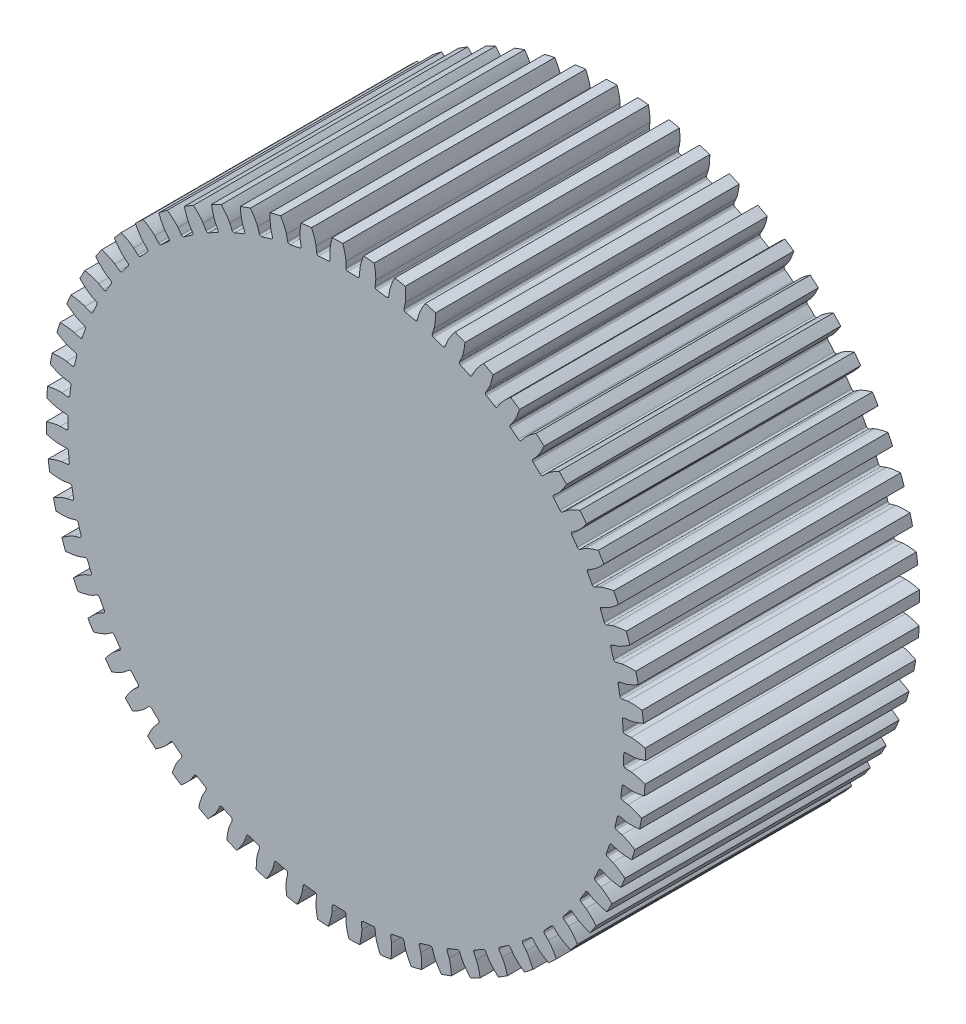
from build123d import *

# Parameters (mm, degrees)
SKETCH1_R                 = 24.045217391
BOSS_EXTRUDE1_DEPTH       = 22.008152455
CUT_EXTRUDE3_START        = -1
CUT_EXTRUDE3_DEPTH        = 24.008152455
FILLET1_R                 = 0.15
CIRPATTERN16_COUNT        = 60
FILLET1_OF_CIRPATTERN16_R = 0.15


with BuildPart() as part:
    # Sketch1 → Boss-Extrude1 (new body)
    with BuildSketch(Plane.XY):
        Circle(SKETCH1_R)
    extrude(amount=BOSS_EXTRUDE1_DEPTH)

    # Sketch2 → Cut-Extrude3 (cut)
    with BuildSketch(Plane.XY.offset(CUT_EXTRUDE3_START)):
        with BuildLine():
            Line((22.916048235, 0), (22.3, 0))
            ThreePointArc((22.3, 0), (22.293369744, -0.543751301), (22.273482917, -1.087179265))
            Line((22.273482917, -1.087179265), (22.888798605, -1.117213115))
            add(Edge.make_bspline(
                [(22.888798605, -1.117213115), (22.905702884, -1.118397162), (22.953024426, -1.122824922), (23.042075226, -1.135557831), (23.186481882, -1.162501344), (23.368907891, -1.205830137), (23.601505715, -1.271830611), (23.790604711, -1.335170026), (23.924319999, -1.384131111), (24.003573033, -1.414553296)],
                knots=[0, 0, 0, 0, 0, 0.005376748, 0.015083688, 0.02853182, 0.046610139, 0.064854849, 0.091796625, 0.091796625, 0.091796625, 0.091796625, 0.091796625], degree=4))
            ThreePointArc((24.003573033, -1.414553296), (24.034804047, -0.707583084), (24.045217391, 0))
            ThreePointArc((24.045217391, 0), (24.044911325, 0.121320867), (24.043993135, 0.242638646))
            add(Edge.make_bspline(
                [(22.916048235, 0), (22.932990139, 0.000358514), (22.980471274, 0.002473968), (23.070036944, 0.010850294), (23.215585447, 0.030721592), (23.399906915, 0.065105151), (23.635445839, 0.119687433), (23.827407927, 0.173732494), (23.963351185, 0.216116414), (24.043993135, 0.242638646)],
                knots=[0, 0, 0, 0, 0, 0.005376748, 0.015083688, 0.02853182, 0.046610139, 0.064854849, 0.091796625, 0.091796625, 0.091796625, 0.091796625, 0.091796625], degree=4))
        make_face()
    cut_extrude3 = extrude(amount=CUT_EXTRUDE3_DEPTH, mode=Mode.SUBTRACT)

    # Fillet1
    fillet1_edges = [part.edges().sort_by_distance(p)[0] for p in [
        (22.3, 0, 11.004076227),
        (22.273482917, -1.087179265, 11.004076227),
    ]]
    fillet(fillet1_edges, radius=FILLET1_R)

    # CirPattern16: Cut-Extrude3 ×60 about axis
    cirpattern16_axis = Axis((0, 0, 22.008152455), (0, 0, -1))
    for i in range(1, CIRPATTERN16_COUNT):
        add(cut_extrude3.rotate(cirpattern16_axis, i * 360 / CIRPATTERN16_COUNT), mode=Mode.SUBTRACT)

    # Fillet1 of CirPattern16
    fillet1_of_cirpattern16_edges = [part.edges().sort_by_distance(p)[0] for p in [
        (22.177838267, -2.330984731, 11.004076227),
        (22.037825269, -3.409436524, 11.004076227),
        (21.812691496, -4.636430705, 11.004076227),
        (21.560716596, -5.694339283, 11.004076227),
        (21.208560313, -6.891078975, 11.004076227),
        (20.8473842, -7.916853669, 11.004076227),
        (20.372063705, -9.070227141, 11.004076227),
        (19.9056435, -10.05262935, 11.004076227),
        (19.312366504, -11.15, 11.004076227),
        (18.745812404, -12.07826632, 11.004076227),
        (18.041078975, -13.107611126, 11.004076227),
        (17.380598265, -13.971571277, 11.004076227),
        (16.572129608, -14.921612522, 11.004076227),
        (15.824958654, -15.711800775, 11.004076227),
        (14.921612522, -16.572129608, 11.004076227),
        (14.095937485, -17.279888496, 11.004076227),
        (13.107611126, -18.041078975, 11.004076227),
        (12.212478275, -18.658654142, 11.004076227),
        (11.15, -19.312366504, 11.004076227),
        (10.195216597, -19.832991669, 11.004076227),
        (9.070227141, -20.372063705, 11.004076227),
        (8.066253992, -20.790034789, 11.004076227),
        (6.891078975, -21.208560313, 11.004076227),
        (5.848915821, -21.519297937, 11.004076227),
        (4.636430705, -21.812691496, 11.004076227),
        (3.567495704, -22.012791154, 11.004076227),
        (2.330984731, -22.177838267, 11.004076227),
        (1.246989358, -22.265107625, 11.004076227),
        (0, -22.3, 11.004076227),
        (-1.087179265, -22.273482917, 11.004076227),
        (-2.330984731, -22.177838267, 11.004076227),
        (-3.409436524, -22.037825269, 11.004076227),
        (-4.636430705, -21.812691496, 11.004076227),
        (-5.694339283, -21.560716596, 11.004076227),
        (-6.891078975, -21.208560313, 11.004076227),
        (-7.916853669, -20.8473842, 11.004076227),
        (-9.070227141, -20.372063705, 11.004076227),
        (-10.05262935, -19.9056435, 11.004076227),
        (-11.15, -19.312366504, 11.004076227),
        (-12.07826632, -18.745812404, 11.004076227),
        (-13.107611126, -18.041078975, 11.004076227),
        (-13.971571277, -17.380598265, 11.004076227),
        (-14.921612522, -16.572129608, 11.004076227),
        (-15.711800775, -15.824958654, 11.004076227),
        (-16.572129608, -14.921612522, 11.004076227),
        (-17.279888496, -14.095937485, 11.004076227),
        (-18.041078975, -13.107611126, 11.004076227),
        (-18.658654142, -12.212478275, 11.004076227),
        (-19.312366504, -11.15, 11.004076227),
        (-19.832991669, -10.195216597, 11.004076227),
        (-20.372063705, -9.070227141, 11.004076227),
        (-20.790034789, -8.066253992, 11.004076227),
        (-21.208560313, -6.891078975, 11.004076227),
        (-21.519297937, -5.848915821, 11.004076227),
        (-21.812691496, -4.636430705, 11.004076227),
        (-22.012791154, -3.567495704, 11.004076227),
        (-22.177838267, -2.330984731, 11.004076227),
        (-22.265107625, -1.246989358, 11.004076227),
        (-22.3, 0, 11.004076227),
        (-22.273482917, 1.087179265, 11.004076227),
        (-22.177838267, 2.330984731, 11.004076227),
        (-22.037825269, 3.409436524, 11.004076227),
        (-21.812691496, 4.636430705, 11.004076227),
        (-21.560716596, 5.694339283, 11.004076227),
        (-21.208560313, 6.891078975, 11.004076227),
        (-20.8473842, 7.916853669, 11.004076227),
        (-20.372063705, 9.070227141, 11.004076227),
        (-19.9056435, 10.05262935, 11.004076227),
        (-19.312366504, 11.15, 11.004076227),
        (-18.745812404, 12.07826632, 11.004076227),
        (-18.041078975, 13.107611126, 11.004076227),
        (-17.380598265, 13.971571277, 11.004076227),
        (-16.572129608, 14.921612522, 11.004076227),
        (-15.824958654, 15.711800775, 11.004076227),
        (-14.921612522, 16.572129608, 11.004076227),
        (-14.095937485, 17.279888496, 11.004076227),
        (-13.107611126, 18.041078975, 11.004076227),
        (-12.212478275, 18.658654142, 11.004076227),
        (-11.15, 19.312366504, 11.004076227),
        (-10.195216597, 19.832991669, 11.004076227),
        (-9.070227141, 20.372063705, 11.004076227),
        (-8.066253992, 20.790034789, 11.004076227),
        (-6.891078975, 21.208560313, 11.004076227),
        (-5.848915821, 21.519297937, 11.004076227),
        (-4.636430705, 21.812691496, 11.004076227),
        (-3.567495704, 22.012791154, 11.004076227),
        (-2.330984731, 22.177838267, 11.004076227),
        (-1.246989358, 22.265107625, 11.004076227),
        (0, 22.3, 11.004076227),
        (1.087179265, 22.273482917, 11.004076227),
        (2.330984731, 22.177838267, 11.004076227),
        (3.409436524, 22.037825269, 11.004076227),
        (4.636430705, 21.812691496, 11.004076227),
        (5.694339283, 21.560716596, 11.004076227),
        (6.891078975, 21.208560313, 11.004076227),
        (7.916853669, 20.8473842, 11.004076227),
        (9.070227141, 20.372063705, 11.004076227),
        (10.05262935, 19.9056435, 11.004076227),
        (11.15, 19.312366504, 11.004076227),
        (12.07826632, 18.745812404, 11.004076227),
        (13.107611126, 18.041078975, 11.004076227),
        (13.971571277, 17.380598265, 11.004076227),
        (14.921612522, 16.572129608, 11.004076227),
        (15.711800775, 15.824958654, 11.004076227),
        (16.572129608, 14.921612522, 11.004076227),
        (17.279888496, 14.095937485, 11.004076227),
        (18.041078975, 13.107611126, 11.004076227),
        (18.658654142, 12.212478275, 11.004076227),
        (19.312366504, 11.15, 11.004076227),
        (19.832991669, 10.195216597, 11.004076227),
        (20.372063705, 9.070227141, 11.004076227),
        (20.790034789, 8.066253992, 11.004076227),
        (21.208560313, 6.891078975, 11.004076227),
        (21.519297937, 5.848915821, 11.004076227),
        (21.812691496, 4.636430705, 11.004076227),
        (22.012791154, 3.567495704, 11.004076227),
        (22.177838267, 2.330984731, 11.004076227),
        (22.265107625, 1.246989358, 11.004076227),
    ]]
    fillet(fillet1_of_cirpattern16_edges, radius=FILLET1_OF_CIRPATTERN16_R)


solid = part.part
